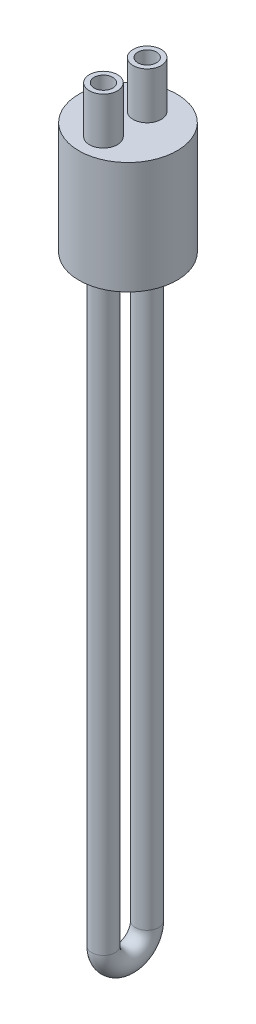
from build123d import *

# Parameters (mm, degrees)
SKETCH1_R           = 21
SKETCH1_R_2         = 4
BOSS_EXTRUDE1_DEPTH = 48
SKETCH2_R           = 19
CUT_EXTRUDE1_DEPTH  = 42
SKETCH3_R           = 6
SKETCH3_R_2         = 4
BOSS_EXTRUDE2_DEPTH = 20
SKETCH7_R           = 5
SKETCH7_R_2         = 4


with BuildPart() as part:
    # Sketch1 → Boss-Extrude1 (new body)
    with BuildSketch(Plane(origin=(0, 0, 0), x_dir=(1, 0, 0), z_dir=(0, 1, 0))):
        Circle(SKETCH1_R)
        with Locations((0, -10.495775772)):
            Circle(SKETCH1_R_2, mode=Mode.SUBTRACT)
        with Locations((0, 8.217839423)):
            Circle(SKETCH1_R_2, mode=Mode.SUBTRACT)
    extrude(amount=BOSS_EXTRUDE1_DEPTH)

    # Sketch2 → Cut-Extrude1 (cut)
    with BuildSketch(Plane.XZ):
        Circle(SKETCH2_R)
    extrude(amount=-CUT_EXTRUDE1_DEPTH, mode=Mode.SUBTRACT)

    # Sketch3 → Boss-Extrude2 (add)
    with BuildSketch(Plane(origin=(0, 48, 0), x_dir=(1, 0, 0), z_dir=(0, 1, 0))):
        with Locations((0, 8.217839423)):
            Circle(SKETCH3_R)
        with Locations((0, 8.217839423)):
            Circle(SKETCH3_R_2, mode=Mode.SUBTRACT)
        with Locations((0, -10.495775772)):
            Circle(SKETCH3_R)
        with Locations((0, -10.495775772)):
            Circle(SKETCH3_R_2, mode=Mode.SUBTRACT)
    extrude(amount=BOSS_EXTRUDE2_DEPTH)

    # Sweep9: sweep along a path in Sketch4
    with BuildLine(Plane(origin=(0, 0, 0), x_dir=(0, 0, -1), z_dir=(1, 0, 0))) as sweep9_path:
        Line((8.160870432, 48), (8.160870432, -252))
        ThreePointArc((8.160870432, -252), (-1.16745267, -261.328323102), (-10.495775772, -252))
        Line((-10.495775772, -252), (-10.495775772, 48))
    # Sketch7 → Sweep9 (sweep)
    with BuildSketch(Plane.XZ.offset(-42)):
        with Locations((0, 10.495775772)):
            Circle(SKETCH7_R)
        with Locations((0, 10.495775772)):
            Circle(SKETCH7_R_2, mode=Mode.SUBTRACT)
    sweep(path=sweep9_path.line)


solid = part.part
